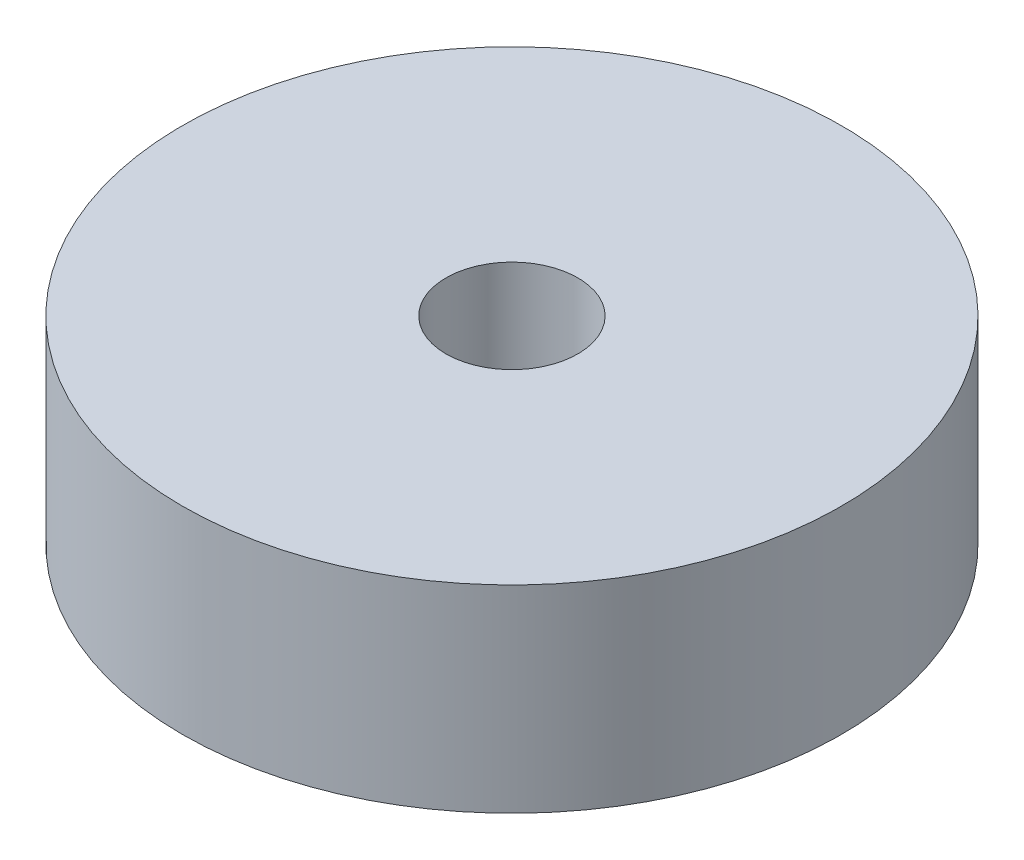
from build123d import *

# Parameters (mm, degrees)
SKETCH3_R           = 10
SKETCH3_R_2         = 2
BOSS_EXTRUDE2_DEPTH = 6


with BuildPart() as part:
    # Sketch3 → Boss-Extrude2 (new body)
    with BuildSketch(Plane(origin=(0, 0, 0), x_dir=(1, 0, 0), z_dir=(0, 1, 0))):
        Circle(SKETCH3_R)
        Circle(SKETCH3_R_2, mode=Mode.SUBTRACT)
    extrude(amount=BOSS_EXTRUDE2_DEPTH)


solid = part.part
